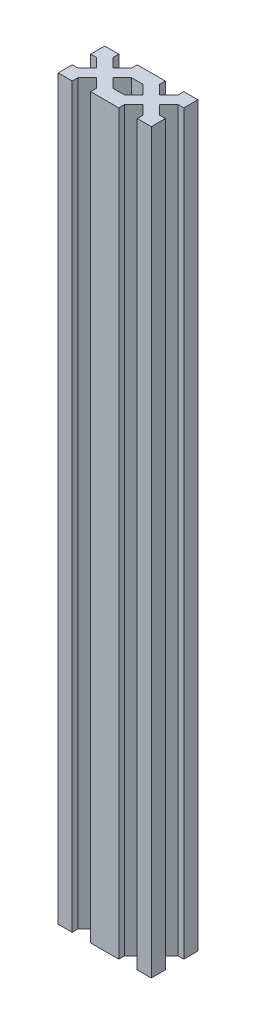
from build123d import *

# Parameters (mm, degrees)
BOSS_EXTRU_2_DEPTH = 316.8


with BuildPart() as part:
    # Esquisse1_3 → Boss.-Extru.2 (new body)
    with BuildSketch(Plane(origin=(0, 0, 0), x_dir=(1, 0, 0), z_dir=(0, 1, 0))):
        Polygon((-6.035533906, 17.5), (-10, 13.535533906), (-13.964466094, 17.5), (-13.964466094, 20), (-20, 20), (-20, 13.964466094), (-17.5, 13.964466094), (-13.535533906, 10), (-17.5, 6.035533906), (-20, 6.035533906), (-20, 0), (-13.964466094, 0), (-13.964466094, 2.5), (-10, 6.464466094), (-6.035533906, 2.5), (-6.035533906, 0), (6.035533906, 0), (6.035533906, 2.5), (10, 6.464466094), (13.964466094, 2.5), (13.964466094, 0), (20, 0), (20, 6.035533906), (17.5, 6.035533906), (13.535533906, 10), (17.5, 13.964466094), (20, 13.964466094), (20, 20), (13.964466094, 20), (13.964466094, 17.5), (10, 13.535533906), (6.035533906, 17.5), (6.035533906, 20), (-6.035533906, 20), align=None)
        Polygon((-6.464466094, 10), (-2.5, 13.964466094), (2.5, 13.964466094), (6.464466094, 10), (2.5, 6.035533906), (-2.5, 6.035533906), align=None, mode=Mode.SUBTRACT)
    extrude(amount=BOSS_EXTRU_2_DEPTH)


solid = part.part
